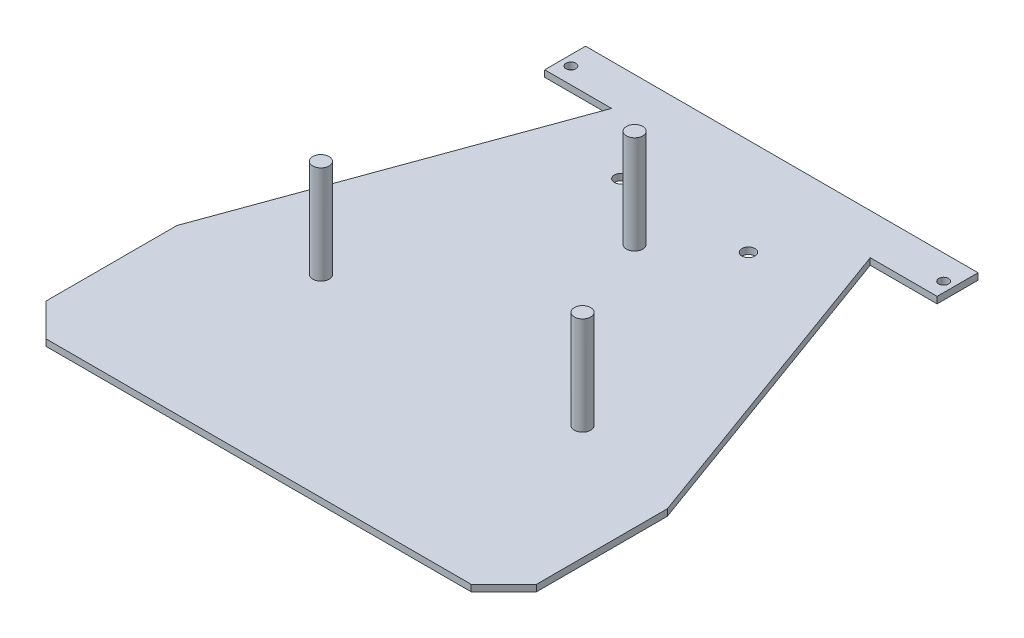
from build123d import *

# Parameters (mm, degrees)
BOSS_EXTRUDE1_DEPTH = 2
CUT_EXTRUDE1_REACH  = 4
SKETCH2_R           = 2
BOSS_EXTRUDE2_DEPTH = 2
CUT_EXTRUDE2_REACH  = 4
SKETCH5_R           = 1.5
SKETCH6_R           = 2.5
BOSS_EXTRUDE3_DEPTH = 30


with BuildPart() as part:
    # Sketch1 → Boss-Extrude1 (new body)
    with BuildSketch(Plane(origin=(0, 0, 0), x_dir=(1, 0, 0), z_dir=(0, 1, 0))):
        Polygon((-75, -70), (-65, -80), (65, -80), (75, -70), (75, -30), (35, 80), (-35, 80), (-75, -30), align=None)
    extrude(amount=BOSS_EXTRUDE1_DEPTH)

    # Sketch2 → Cut-Extrude1 (cut, up to next)
    with BuildSketch(Plane.XZ, mode=Mode.PRIVATE) as cut_extrude1_sk1:
        with Locations((-19.5, -50.31270399)):
            Circle(SKETCH2_R)
    cut_extrude1_tool1 = extrude(cut_extrude1_sk1.sketch, amount=-CUT_EXTRUDE1_REACH, mode=Mode.PRIVATE) & part.part
    add(cut_extrude1_tool1.solids().sort_by_distance((-19.5, 0, -50.312704))[0], mode=Mode.SUBTRACT)
    # Sketch2 → Cut-Extrude1 (cut, up to next)
    with BuildSketch(Plane.XZ, mode=Mode.PRIVATE) as cut_extrude1_sk2:
        with Locations((19.5, -50.31270399)):
            Circle(SKETCH2_R)
    cut_extrude1_tool2 = extrude(cut_extrude1_sk2.sketch, amount=-CUT_EXTRUDE1_REACH, mode=Mode.PRIVATE) & part.part
    add(cut_extrude1_tool2.solids().sort_by_distance((19.5, 0, -50.312704))[0], mode=Mode.SUBTRACT)

    # Sketch3 → Boss-Extrude2 (add)
    with BuildSketch(Plane.XZ):
        Polygon((-35, -80), (-60, -80), (-60, -67.5), (60, -67.5), (60, -80), align=None)
    extrude(amount=-BOSS_EXTRUDE2_DEPTH)

    # Sketch5 → Cut-Extrude2 (cut, up to next)
    with BuildSketch(Plane(origin=(0, 2, 0), x_dir=(1, 0, 0), z_dir=(0, 1, 0)), mode=Mode.PRIVATE) as cut_extrude2_sk1:
        with Locations((57, 72.5)):
            Circle(SKETCH5_R)
    cut_extrude2_tool1 = extrude(cut_extrude2_sk1.sketch, amount=-CUT_EXTRUDE2_REACH, mode=Mode.PRIVATE) & part.part
    add(cut_extrude2_tool1.solids().sort_by_distance((57, 2, -72.5))[0], mode=Mode.SUBTRACT)
    # Sketch5 → Cut-Extrude2 (cut, up to next)
    with BuildSketch(Plane(origin=(0, 2, 0), x_dir=(1, 0, 0), z_dir=(0, 1, 0)), mode=Mode.PRIVATE) as cut_extrude2_sk2:
        with Locations((-57, 72.5)):
            Circle(SKETCH5_R)
    cut_extrude2_tool2 = extrude(cut_extrude2_sk2.sketch, amount=-CUT_EXTRUDE2_REACH, mode=Mode.PRIVATE) & part.part
    add(cut_extrude2_tool2.solids().sort_by_distance((-57, 2, -72.5))[0], mode=Mode.SUBTRACT)

    # Sketch6 → Boss-Extrude3 (add)
    with BuildSketch(Plane(origin=(0, 2, 0), x_dir=(1, 0, 0), z_dir=(0, 1, 0))):
        with Locations((-40, -20.935279196)):
            Circle(SKETCH6_R)
        with Locations((40, -20.935279196)):
            Circle(SKETCH6_R)
        with Locations((0, 35)):
            Circle(SKETCH6_R)
    extrude(amount=BOSS_EXTRUDE3_DEPTH)


solid = part.part
